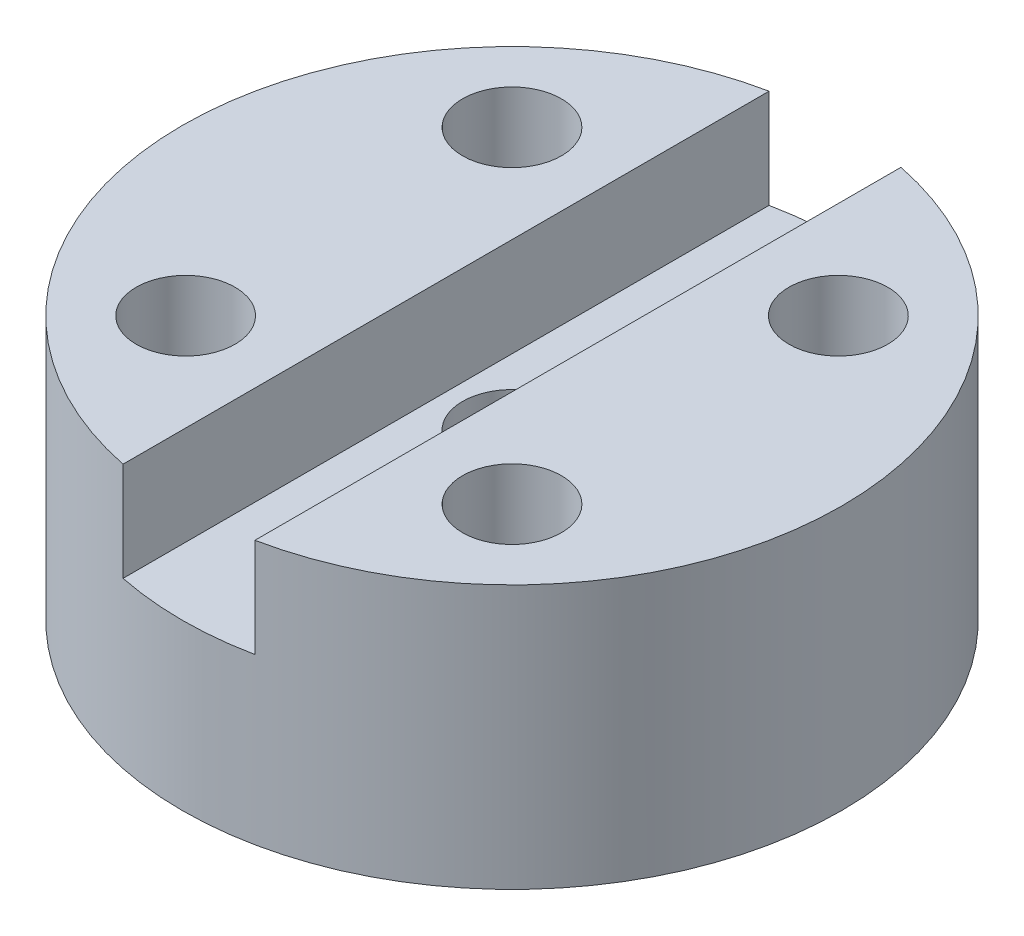
from build123d import *

# Parameters (mm, degrees)
SKIZZE1_R                       = 10
SKIZZE1_R_2                     = 1.5
AUFSATZ_LINEAR_AUSTRAGEN1_DEPTH = 8
SKIZZE2_W                       = 4
SKIZZE2_H                       = 22.736350236
SCHNITT_LINEAR_AUSTRAGEN1_DEPTH = 3
SKIZZE3_R                       = 3.5
SCHNITT_LINEAR_AUSTRAGEN2_DEPTH = 3


with BuildPart() as part:
    # Skizze1 → Aufsatz-Linear austragen1 (new body)
    with BuildSketch(Plane(origin=(0, 0, 0), x_dir=(1, 0, 0), z_dir=(0, 1, 0))):
        Circle(SKIZZE1_R)
        with Locations((4.949747468, 4.949747468)):
            Circle(SKIZZE1_R_2, mode=Mode.SUBTRACT)
        with Locations((-4.949747468, 4.949747468)):
            Circle(SKIZZE1_R_2, mode=Mode.SUBTRACT)
        with Locations((-4.949747468, -4.949747468)):
            Circle(SKIZZE1_R_2, mode=Mode.SUBTRACT)
        with Locations((4.949747468, -4.949747468)):
            Circle(SKIZZE1_R_2, mode=Mode.SUBTRACT)
        Circle(SKIZZE1_R_2, mode=Mode.SUBTRACT)
    extrude(amount=AUFSATZ_LINEAR_AUSTRAGEN1_DEPTH)

    # Skizze2 → Schnitt-Linear austragen1 (cut)
    with BuildSketch(Plane(origin=(0, 8, 0), x_dir=(1, 0, 0), z_dir=(0, 1, 0))):
        Rectangle(SKIZZE2_W, SKIZZE2_H)
    extrude(amount=-SCHNITT_LINEAR_AUSTRAGEN1_DEPTH, mode=Mode.SUBTRACT)

    # Skizze3 → Schnitt-Linear austragen2 (cut)
    with BuildSketch(Plane.XZ):
        Circle(SKIZZE3_R)
    extrude(amount=-SCHNITT_LINEAR_AUSTRAGEN2_DEPTH, mode=Mode.SUBTRACT)


solid = part.part
